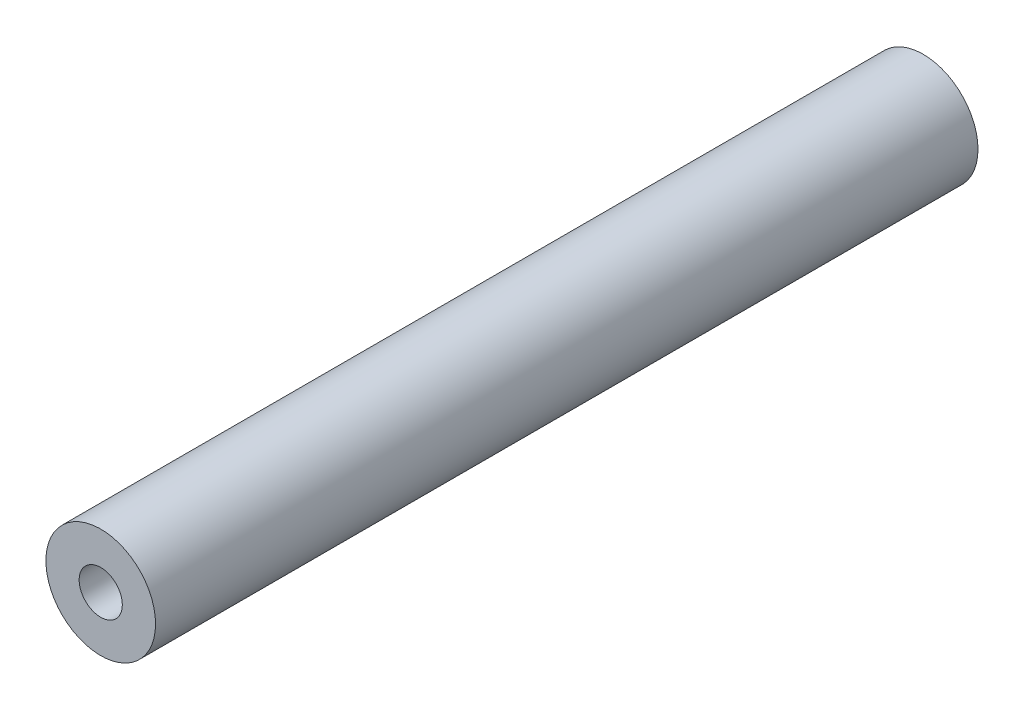
from build123d import *

# Parameters (mm, degrees)
SKETCH1_R           = 2.54
SKETCH1_R_2         = 1
BOSS_EXTRUDE1_DEPTH = 38.1


with BuildPart() as part:
    # Sketch1 → Boss-Extrude1 (new body)
    with BuildSketch(Plane.XY.offset(48.35)):
        with Locations((53.780969954, -135.449923089)):
            Circle(SKETCH1_R)
        with Locations((53.780969954, -135.449923089)):
            Circle(SKETCH1_R_2, mode=Mode.SUBTRACT)
    extrude(amount=-BOSS_EXTRUDE1_DEPTH)


solid = part.part
